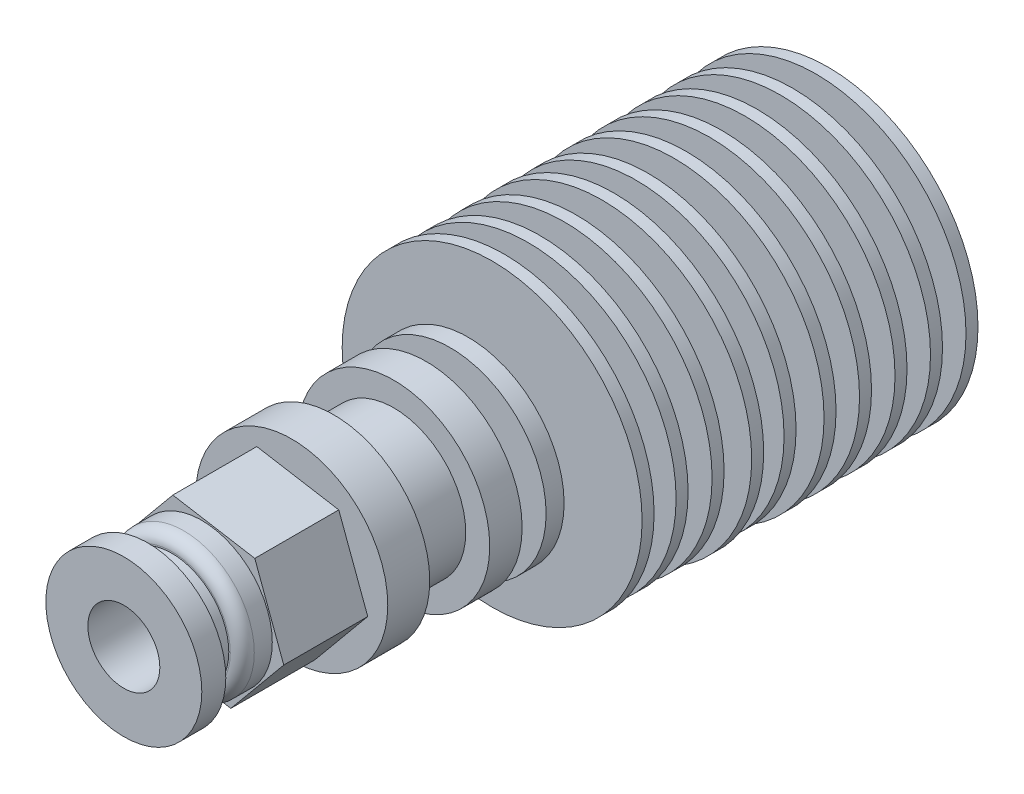
from build123d import *

# Parameters (mm, degrees)
SKETCH1_R            = 12.5
BOSS_EXTRUDE1_DEPTH  = 1
SKETCH2_R            = 7.5
BOSS_EXTRUDE2_DEPTH  = 2
LPATTERN2_COUNT      = 5
LPATTERN2_PITCH      = 3
SKETCH4_R            = 12.334130066
BOSS_EXTRUDE3_DEPTH  = 1
SKETCH5_R            = 6.5
BOSS_EXTRUDE4_DEPTH  = 2
SKETCH6_R            = 12.484493424
BOSS_EXTRUDE5_DEPTH  = 1
SKETCH7_R            = 5
BOSS_EXTRUDE6_DEPTH  = 2
SKETCH8_R            = 12.334130066
BOSS_EXTRUDE7_DEPTH  = 1
SKETCH9_R            = 5
BOSS_EXTRUDE8_DEPTH  = 2
SKETCH10_R           = 12.334130066
BOSS_EXTRUDE9_DEPTH  = 1
SKETCH11_R           = 5
BOSS_EXTRUDE10_DEPTH = 2
SKETCH12_R           = 12.5
BOSS_EXTRUDE11_DEPTH = 1
SKETCH13_R           = 5
BOSS_EXTRUDE12_DEPTH = 2
SKETCH14_R           = 8
BOSS_EXTRUDE13_DEPTH = 1.5
SKETCH15_R           = 5
BOSS_EXTRUDE14_DEPTH = 2
SKETCH16_R           = 8
BOSS_EXTRUDE15_DEPTH = 2.7
SKETCH17_R           = 6
BOSS_EXTRUDE16_DEPTH = 5
SKETCH18_R           = 8
BOSS_EXTRUDE17_DEPTH = 3.5
SKETCH19_R           = 5
BOSS_EXTRUDE18_DEPTH = 0.5
BOSS_EXTRUDE19_DEPTH = 7
SKETCH21_R           = 5.875
BOSS_EXTRUDE20_DEPTH = 2.5
SKETCH22_R           = 4.75
BOSS_EXTRUDE21_DEPTH = 1
SKETCH23_R           = 4
BOSS_EXTRUDE22_DEPTH = 1
SKETCH24_R           = 6.5
BOSS_EXTRUDE23_DEPTH = 2
FILLET1_R            = 1
SKETCH27_R           = 2.875
CUT_EXTRUDE3_DEPTH   = 20
SKETCH28_R           = 1
CUT_EXTRUDE4_DEPTH   = 35
SKETCH29_R           = 3
CUT_EXTRUDE5_DEPTH   = 35


with BuildPart() as part:
    # Sketch1 → Boss-Extrude1 (new body)
    with BuildSketch(Plane.XY):
        Circle(SKETCH1_R)
    extrude(amount=BOSS_EXTRUDE1_DEPTH)

    # Sketch2 → Boss-Extrude2 (add)
    with BuildSketch(Plane.XY.offset(1)):
        Circle(SKETCH2_R)
    extrude(amount=BOSS_EXTRUDE2_DEPTH)


with BuildPart() as lpattern2_1:
    # LPattern2: pattern copy
    add(part.part.moved(Location(Vector(0.013822494, 0, 0.999904465) * (1 * LPATTERN2_PITCH))))


with BuildPart() as lpattern2_2:
    # LPattern2: pattern copy
    add(part.part.moved(Location(Vector(0.013822494, 0, 0.999904465) * (2 * LPATTERN2_PITCH))))


with BuildPart() as lpattern2_3:
    # LPattern2: pattern copy
    add(part.part.moved(Location(Vector(0.013822494, 0, 0.999904465) * (3 * LPATTERN2_PITCH))))


with BuildPart() as lpattern2_4:
    # LPattern2: pattern copy
    add(part.part.moved(Location(Vector(0.013822494, 0, 0.999904465) * (4 * LPATTERN2_PITCH))))

    # Sketch4 → Boss-Extrude3 (add)
    with BuildSketch(Plane.XY.offset(14.998853577)):
        Circle(SKETCH4_R)
    extrude(amount=BOSS_EXTRUDE3_DEPTH)

    # Sketch5 → Boss-Extrude4 (add)
    with BuildSketch(Plane.XY.offset(15.998853577)):
        Circle(SKETCH5_R)
    extrude(amount=BOSS_EXTRUDE4_DEPTH)

    # Sketch6 → Boss-Extrude5 (add)
    with BuildSketch(Plane.XY.offset(17.998853577)):
        with Locations((0.150363357, 0)):
            Circle(SKETCH6_R)
    extrude(amount=BOSS_EXTRUDE5_DEPTH)

    # Sketch7 → Boss-Extrude6 (add)
    with BuildSketch(Plane.XY.offset(18.998853577)):
        Circle(SKETCH7_R)
    extrude(amount=BOSS_EXTRUDE6_DEPTH)

    # Sketch8 → Boss-Extrude7 (add)
    with BuildSketch(Plane.XY.offset(20.998853577)):
        Circle(SKETCH8_R)
    extrude(amount=BOSS_EXTRUDE7_DEPTH)

    # Sketch9 → Boss-Extrude8 (add)
    with BuildSketch(Plane.XY.offset(21.998853577)):
        Circle(SKETCH9_R)
    extrude(amount=BOSS_EXTRUDE8_DEPTH)

    # Sketch10 → Boss-Extrude9 (add)
    with BuildSketch(Plane.XY.offset(23.998853577)):
        Circle(SKETCH10_R)
    extrude(amount=BOSS_EXTRUDE9_DEPTH)

    # Sketch11 → Boss-Extrude10 (add)
    with BuildSketch(Plane.XY.offset(24.998853577)):
        Circle(SKETCH11_R)
    extrude(amount=BOSS_EXTRUDE10_DEPTH)

    # Sketch12 → Boss-Extrude11 (add)
    with BuildSketch(Plane.XY.offset(26.998853577)):
        Circle(SKETCH12_R)
    extrude(amount=BOSS_EXTRUDE11_DEPTH)

    # Sketch13 → Boss-Extrude12 (add)
    with BuildSketch(Plane.XY.offset(27.998853577)):
        Circle(SKETCH13_R)
    extrude(amount=BOSS_EXTRUDE12_DEPTH)

    # Sketch14 → Boss-Extrude13 (add)
    with BuildSketch(Plane.XY.offset(29.998853577)):
        Circle(SKETCH14_R)
    extrude(amount=BOSS_EXTRUDE13_DEPTH)

    # Sketch15 → Boss-Extrude14 (add)
    with BuildSketch(Plane.XY.offset(31.498853577)):
        Circle(SKETCH15_R)
    extrude(amount=BOSS_EXTRUDE14_DEPTH)

    # Sketch16 → Boss-Extrude15 (add)
    with BuildSketch(Plane.XY.offset(33.498853577)):
        Circle(SKETCH16_R)
    extrude(amount=BOSS_EXTRUDE15_DEPTH)

    # Sketch17 → Boss-Extrude16 (add)
    with BuildSketch(Plane.XY.offset(36.198853577)):
        Circle(SKETCH17_R)
    extrude(amount=BOSS_EXTRUDE16_DEPTH)

    # Sketch18 → Boss-Extrude17 (add)
    with BuildSketch(Plane.XY.offset(41.198853577)):
        Circle(SKETCH18_R)
    extrude(amount=BOSS_EXTRUDE17_DEPTH)

    # Sketch19 → Boss-Extrude18 (add)
    with BuildSketch(Plane.XY.offset(44.698853577)):
        Circle(SKETCH19_R)
    extrude(amount=BOSS_EXTRUDE18_DEPTH)

    # Sketch20 → Boss-Extrude19 (add)
    with BuildSketch(Plane.XY.offset(45.198853577)):
        Polygon((2.415530921, -6.493474445), (6.831279289, -1.154826082), (4.415748368, 5.338648364), (-2.415530921, 6.493474445), (-6.831279289, 1.154826082), (-4.415748368, -5.338648364), align=None)
    extrude(amount=BOSS_EXTRUDE19_DEPTH)

    # Sketch21 → Boss-Extrude20 (add)
    with BuildSketch(Plane.XY.offset(52.198853577)):
        Circle(SKETCH21_R)
    extrude(amount=BOSS_EXTRUDE20_DEPTH)

    # Sketch22 → Boss-Extrude21 (add)
    with BuildSketch(Plane.XY.offset(54.698853577)):
        Circle(SKETCH22_R)
    extrude(amount=BOSS_EXTRUDE21_DEPTH)

    # Sketch23 → Boss-Extrude22 (add)
    with BuildSketch(Plane.XY.offset(55.698853577)):
        Circle(SKETCH23_R)
    extrude(amount=BOSS_EXTRUDE22_DEPTH)

    # Sketch24 → Boss-Extrude23 (add)
    with BuildSketch(Plane.XY.offset(56.698853577)):
        Circle(SKETCH24_R)
    extrude(amount=BOSS_EXTRUDE23_DEPTH)

    # Fillet1
    fillet1_edges = [lpattern2_4.edges().sort_by_distance(p)[0] for p in [
        (-5.875, 0, 54.698853577),
    ]]
    fillet(fillet1_edges, radius=FILLET1_R)


with BuildPart() as cut_extrude3_tool:
    # Sketch27 → Cut-Extrude3 (new body)
    with BuildSketch(Plane(origin=(0, 0, 0), x_dir=(-1, 0, 0), z_dir=(0, 0, -1))):
        Circle(SKETCH27_R)
    extrude(amount=-CUT_EXTRUDE3_DEPTH)


with BuildPart() as part_1:
    add(part.part)

    # Cut-Extrude3: cut by cut_extrude3_tool
    add(cut_extrude3_tool.part, mode=Mode.SUBTRACT)


with BuildPart() as lpattern2_1_1:
    add(lpattern2_1.part)

    # Cut-Extrude3: cut by cut_extrude3_tool
    add(cut_extrude3_tool.part, mode=Mode.SUBTRACT)


with BuildPart() as lpattern2_2_1:
    add(lpattern2_2.part)

    # Cut-Extrude3: cut by cut_extrude3_tool
    add(cut_extrude3_tool.part, mode=Mode.SUBTRACT)


with BuildPart() as lpattern2_3_1:
    add(lpattern2_3.part)

    # Cut-Extrude3: cut by cut_extrude3_tool
    add(cut_extrude3_tool.part, mode=Mode.SUBTRACT)


with BuildPart() as lpattern2_4_1:
    add(lpattern2_4.part)

    # Cut-Extrude3: cut by cut_extrude3_tool
    add(cut_extrude3_tool.part, mode=Mode.SUBTRACT)

    # Sketch28 → Cut-Extrude4 (cut)
    with BuildSketch(Plane(origin=(0, 0, 20), x_dir=(-1, 0, 0), z_dir=(0, 0, -1))):
        Circle(SKETCH28_R)
    extrude(amount=-CUT_EXTRUDE4_DEPTH, mode=Mode.SUBTRACT)

    # Sketch29 → Cut-Extrude5 (cut)
    with BuildSketch(Plane.XY.offset(58.698853577)):
        Circle(SKETCH29_R)
    extrude(amount=-CUT_EXTRUDE5_DEPTH, mode=Mode.SUBTRACT)


solid = Compound([part_1.part, lpattern2_1_1.part, lpattern2_2_1.part, lpattern2_3_1.part, lpattern2_4_1.part])
